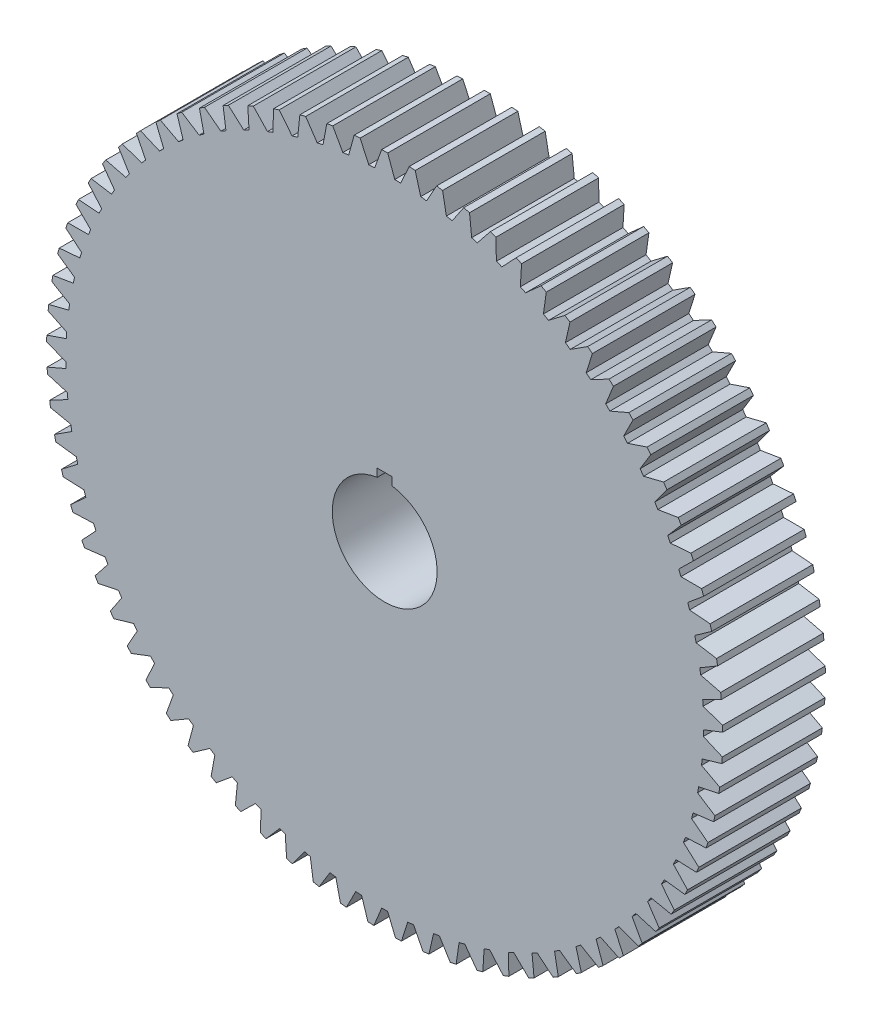
from build123d import *

# Parameters (mm, degrees)
BOSS_EXTRUDE1_DEPTH = 43.5102


with BuildPart() as part:
    # Sketch2 → Boss-Extrude1 (new body)
    with BuildSketch(Plane.XY):
        with BuildLine():
            Line((1.27, 143.32657345), (4.264662636, 135.098805479))
            ThreePointArc((4.264662636, 135.098805479), (5.513234102, 135.053614683), (6.76133452, 134.996884945))
            Line((6.76133452, 134.996884945), (10.416672135, 142.95318289))
            ThreePointArc((10.416672135, 142.95318289), (11.682904931, 142.855273929), (12.948220495, 142.74614931))
            Line((12.948220495, 142.74614931), (15.262279165, 134.301665752))
            ThreePointArc((15.262279165, 134.301665752), (16.503012644, 134.15485516), (17.74233611, 133.996582414))
            Line((17.74233611, 133.996582414), (22.034023036, 141.628462484))
            ThreePointArc((22.034023036, 141.628462484), (23.288062058, 141.427669579), (24.540272719, 141.215773098))
            Line((24.540272719, 141.215773098), (26.158327745, 132.610770599))
            ThreePointArc((26.158327745, 132.610770599), (27.382966359, 132.363317209), (28.605265381, 132.104554735))
            Line((28.605265381, 132.104554735), (33.504741149, 139.361228028))
            ThreePointArc((33.504741149, 139.361228028), (34.738240973, 139.058887422), (35.969013476, 138.745629215))
            Line((35.969013476, 138.745629215), (36.88029697, 130.037372646))
            ThreePointArc((36.88029697, 130.037372646), (38.080690951, 129.690923221), (39.277831329, 129.33339304))
            Line((39.277831329, 129.33339304), (44.752490738, 136.166567591))
            ThreePointArc((44.752490738, 136.166567591), (45.957242627, 135.764691312), (47.158386384, 135.352156062))
            Line((47.158386384, 135.352156062), (47.356833903, 126.598597433))
            ThreePointArc((47.356833903, 126.598597433), (48.524994828, 126.155457536), (49.689009791, 125.701538953))
            Line((49.689009791, 125.701538953), (55.702419884, 132.065741114))
            ThreePointArc((55.702419884, 132.065741114), (56.870406413, 131.567003581), (58.033928011, 131.057936641))
            Line((58.033928011, 131.057936641), (57.518218919, 122.317329441))
            ThreePointArc((57.518218919, 122.317329441), (58.64637287, 121.780448096), (59.769516091, 121.233161864))
            Line((59.769516091, 121.233161864), (66.281658616, 127.086038918))
            ThreePointArc((66.281658616, 127.086038918), (67.405107027, 126.493759148), (68.523263421, 125.891548274))
            Line((68.523263421, 125.891548274), (67.296829679, 117.222059803))
            ThreePointArc((67.296829679, 117.222059803), (68.377468977, 116.595009866), (69.452266123, 115.957998084))
            Line((69.452266123, 115.957998084), (76.419803846, 121.260600101))
            ThreePointArc((76.419803846, 121.260600101), (77.491237776, 120.578719618), (78.55658782, 119.887372425))
            Line((78.55658782, 119.887372425), (76.62759114, 111.346696697))
            ThreePointArc((76.62759114, 111.346696697), (77.653524309, 110.633651082), (78.672822782, 109.911152959))
            Line((78.672822782, 109.911152959), (86.04938789, 114.628191997))
            ThreePointArc((86.04938789, 114.628191997), (87.061677122, 113.861248604), (88.067131087, 113.085365892))
            Line((88.067131087, 113.085365892), (85.448408625, 104.730339695))
            ThreePointArc((85.448408625, 104.730339695), (86.412808248, 103.936043603), (87.369824786, 103.132867245))
            Line((87.369824786, 103.132867245), (95.106327454, 107.232952188))
            ThreePointArc((95.106327454, 107.232952188), (96.052735371, 106.386049765), (96.991602127, 105.530794907))
            Line((96.991602127, 105.530794907), (93.700581048, 97.417019562))
            ThreePointArc((93.700581048, 97.417019562), (94.597029206, 96.546758902), (95.48539502, 95.668249315))
            Line((95.48539502, 95.668249315), (103.530350101, 99.124094774))
            ThreePointArc((103.530350101, 99.124094774), (104.404578513, 98.202869318), (105.270610057, 97.273933893))
            Line((105.270610057, 97.273933893), (101.329191565, 89.455405237))
            ThreePointArc((101.329191565, 89.455405237), (102.151722542, 88.514971451), (102.965525705, 87.56697497))
            Line((102.965525705, 87.56697497), (111.265395349, 90.355582864))
            ThreePointArc((111.265395349, 90.355582864), (112.061626411, 89.366164978), (112.849059446, 88.369730899))
            Line((112.849059446, 88.369730899), (108.283473029, 80.898479949))
            ThreePointArc((108.283473029, 80.898479949), (109.026613018, 79.894131467), (109.760437805, 78.882956854))
            Line((109.760437805, 78.882956854), (118.259987748, 80.985769457))
            ThreePointArc((118.259987748, 80.985769457), (118.972922675, 79.934743554), (119.676516962, 78.877441925))
            Line((119.676516962, 78.877441925), (114.517145846, 71.803188624))
            ThreePointArc((114.517145846, 71.803188624), (115.175949373, 70.741609221), (115.8249123, 69.673985676))
            Line((115.8249123, 69.673985676), (124.467579441, 71.077009117))
            ThreePointArc((124.467579441, 71.077009117), (125.092473767, 69.971369601), (125.707547004, 68.860236588))
            Line((125.707547004, 68.860236588), (119.988725951, 62.230058925))
            ThreePointArc((119.988725951, 62.230058925), (120.558808788, 61.118313237), (121.118591113, 60.001345617))
            Line((121.118591113, 60.001345617), (129.846859928, 60.695243007))
            ThreePointArc((129.846859928, 60.695243007), (130.379555085, 59.542347727), (130.902014061, 58.384777739))
            Line((130.902014061, 58.384777739), (124.661800882, 52.242798452))
            ThreePointArc((124.661800882, 52.242798452), (125.13936922, 51.088284962), (125.606245686, 49.929406504))
            Line((125.606245686, 49.929406504), (134.362030985, 49.90956007))
            ThreePointArc((134.362030985, 49.90956007), (134.798981974, 48.717081352), (135.225349811, 47.520777827))
            Line((135.225349811, 47.520777827), (128.505272096, 41.907870774))
            ThreePointArc((128.505272096, 41.907870774), (128.887147797, 40.71827258), (129.258011418, 39.525195428))
            Line((129.258011418, 39.525195428), (137.983044895, 38.791737244))
            ThreePointArc((137.983044895, 38.791737244), (138.32134388, 37.567610839), (138.648783169, 36.340534978))
            Line((138.648783169, 36.340534978), (131.493561926, 31.29405313))
            ThreePointArc((131.493561926, 31.29405313), (131.777203671, 30.077286811), (132.049586409, 28.857950697))
            Line((132.049586409, 28.857950697), (140.685804406, 27.415761808))
            ThreePointArc((140.685804406, 27.415761808), (140.923200063, 26.168134075), (141.149531751, 24.918451865))
            Line((141.149531751, 24.918451865), (133.606783796, 20.471978727))
            ThreePointArc((133.606783796, 20.471978727), (133.790303995, 19.236141662), (133.962393189, 17.998661066))
            Line((133.962393189, 17.998661066), (142.4523231, 15.857338999))
            ThreePointArc((142.4523231, 15.857338999), (142.5872356, 14.594512695), (142.710953487, 13.330540566))
            Line((142.710953487, 13.330540566), (134.830874563, 9.513666682))
            ThreePointArc((134.830874563, 9.513666682), (134.913051921, 8.266983163), (134.983702346, 7.019593315))
            Line((134.983702346, 7.019593315), (143.270845088, 4.193388216))
            ThreePointArc((143.270845088, 4.193388216), (143.30237661, 2.923767241), (143.322657373, 1.653916719))
            Line((143.322657373, 1.653916719), (135.157688106, -1.507957245))
            ThreePointArc((135.157688106, -1.507957245), (135.137975745, -2.757190745), (135.106717233, -4.006188672))
            Line((135.106717233, -4.006188672), (143.135923239, -7.498468873))
            ThreePointArc((143.135923239, -7.498468873), (143.063863946, -8.766435401), (142.98057262, -10.033713671))
            Line((142.98057262, -10.033713671), (134.585049534, -12.519545965))
            ThreePointArc((134.585049534, -12.519545965), (134.463578636, -13.763016003), (134.330619209, -15.005310133))
            Line((134.330619209, -15.005310133), (142.048455436, -19.14042489))
            ThreePointArc((142.048455436, -19.14042489), (141.873284872, -20.398298862), (141.686975747, -21.654571352))
            Line((141.686975747, -21.654571352), (133.116769662, -23.447819172))
            ThreePointArc((133.116769662, -23.447819172), (132.894348597, -24.677250661), (132.660573076, -25.904573732))
            Line((132.660573076, -25.904573732), (140.0156786, -30.655004536))
            ThreePointArc((140.0156786, -30.655004536), (139.738562494, -31.89441501), (139.450475427, -33.131321433))
            Line((139.450475427, -33.131321433), (130.762619651, -34.220051011))
            ThreePointArc((130.762619651, -34.220051011), (130.440728594, -35.427262286), (130.107692718, -36.631446666))
            Line((130.107692718, -36.631446666), (137.051120523, -41.965580186))
            ThreePointArc((137.051120523, -41.965580186), (136.673903039, -43.178279088), (136.285955201, -44.387588037))
            Line((136.285955201, -44.387588037), (127.53826598, -44.764554057))
            ThreePointArc((127.53826598, -44.764554057), (127.119047063, -45.941511327), (126.68896713, -47.114543367))
            Line((126.68896713, -47.114543367), (133.174509851, -52.996881823))
            ThreePointArc((133.174509851, -52.996881823), (132.699701308, -54.174798843), (132.214474429, -55.348462565))
            Line((132.214474429, -55.348462565), (123.465166192, -55.011156381))
            ThreePointArc((123.465166192, -55.011156381), (122.951409247, -56.150027189), (122.427147369, -57.284100554))
            Line((122.427147369, -57.284100554), (128.411644788, -63.675497955))
            ThreePointArc((128.411644788, -63.675497955), (127.842404959, -64.810794249), (127.263128143, -65.941002207))
            Line((127.263128143, -65.941002207), (118.570426093, -64.891668536))
            ThreePointArc((118.570426093, -64.891668536), (117.965550088, -65.984873884), (117.350595141, -67.072441504))
            Line((117.350595141, -67.072441504), (122.794221415, -73.930364154))
            ThreePointArc((122.794221415, -73.930364154), (122.134338497, -75.015484513), (121.464866736, -76.094715359))
            Line((121.464866736, -76.094715359), (112.886619371, -74.340337342))
            ThreePointArc((112.886619371, -74.340337342), (112.194649657, -75.380602131), (111.493094063, -76.414426422))
            Line((111.493094063, -76.414426422), (116.359622758, -83.693235977))
            ThreePointArc((116.359622758, -83.693235977), (115.613488164, -84.720959104), (114.858276682, -85.742030735))
            Line((114.858276682, -85.742030735), (106.451570822, -83.29428347))
            ThreePointArc((106.451570822, -83.29428347), (105.677112342, -84.274684907), (104.89362484, -85.247885939))
            Line((104.89362484, -85.247885939), (109.15067001, -92.899143124))
            ThreePointArc((109.15067001, -92.899143124), (108.323249141, -93.86262969), (107.487323746, -94.818747043))
            Line((107.487323746, -94.818747043), (99.308104633, -91.693919883))
            ThreePointArc((99.308104633, -91.693919883), (98.456311281, -92.60793356), (97.59610585, -93.514034841))
            Line((97.59610585, -93.514034841), (101.215337562, -101.4868218))
            ThreePointArc((101.215337562, -101.4868218), (100.312136768, -102.379659962), (99.401060405, -103.264460233))
            Line((99.401060405, -103.264460233), (91.503759392, -99.483348388))
            ThreePointArc((91.503759392, -99.483348388), (90.580299712, -100.324891693), (89.649100877, -101.157863269))
            Line((89.649100877, -101.157863269), (92.606433742, -109.399122421))
            ThreePointArc((92.606433742, -109.399122421), (91.633463675, -110.215370488), (90.653299407, -111.022965477))
            Line((90.653299407, -111.022965477), (83.090471729, -106.610731623))
            ThreePointArc((83.090471729, -106.610731623), (82.101491193, -107.374204226), (81.105495929, -108.128502807))
            Line((81.105495929, -108.128502807), (83.381249384, -116.583389932))
            ThreePointArc((83.381249384, -116.583389932), (82.344984999, -117.317615908), (81.302255659, -118.042631204))
            Line((81.302255659, -118.042631204), (74.124230686, -113.028638028))
            ThreePointArc((74.124230686, -113.028638028), (73.076310796, -113.708959144), (72.022147288, -114.379564999))
            Line((72.022147288, -114.379564999), (73.601176568, -122.991814218))
            ThreePointArc((73.601176568, -122.991814218), (72.508514034, -123.63913195), (71.410158812, -124.276742696))
            Line((71.410158812, -124.276742696), (64.664705117, -118.694357496))
            ThreePointArc((64.664705117, -118.694357496), (63.564819608, -119.2869997), (62.459503138, -119.869450057))
            Line((62.459503138, -119.869450057), (63.331300066, -128.581748273))
            ThreePointArc((63.331300066, -128.581748273), (62.189510872, -129.137849968), (61.042839141, -129.68381297))
            Line((61.042839141, -129.68381297), (54.774846604, -123.570185598))
            ThreePointArc((54.774846604, -123.570185598), (53.630315032, -124.071204954), (52.481201301, -124.561623702))
            Line((52.481201301, -124.561623702), (52.63996421, -133.315992007))
            ThreePointArc((52.63996421, -133.315992007), (51.456646775, -133.777176901), (50.269289447, -134.227858865))
            Line((50.269289447, -134.227858865), (44.520470525, -127.623674502))
            ThreePointArc((44.520470525, -127.623674502), (43.338909559, -128.029736809), (42.153645728, -128.424860292))
            Line((42.153645728, -128.424860292), (41.598318078, -137.16303981))
            ThreePointArc((41.598318078, -137.16303981), (40.381347184, -137.526238793), (39.161205925, -137.878640504))
            Line((39.161205925, -137.878640504), (33.96981806, -130.827848909))
            ThreePointArc((33.96981806, -130.827848909), (32.759090792, -131.13625189), (31.545564597, -131.433450626))
            Line((31.545564597, -131.433450626), (30.279842002, -140.097290214))
            ThreePointArc((30.279842002, -140.097290214), (29.037316389, -140.360086256), (27.792511039, -140.61186254))
            Line((27.792511039, -140.61186254), (23.19310206, -133.161385567))
            ThreePointArc((23.19310206, -133.161385567), (21.961265681, -133.37007685), (20.727552938, -133.567373031))
            Line((20.727552938, -133.567373031), (18.759858573, -142.099216265))
            ThreePointArc((18.759858573, -142.099216265), (17.500047045, -142.259860503), (16.238861577, -142.40933583))
            Line((16.238861577, -142.40933583), (12.262039792, -134.608755173))
            ThreePointArc((12.262039792, -134.608755173), (11.017291971, -134.716345953), (9.771602835, -134.812426605))
            Line((9.771602835, -134.812426605), (7.115031381, -143.155495477))
            ThreePointArc((7.115031381, -143.155495477), (5.846317775, -143.212918849), (4.577145171, -143.259098486))
            Line((4.577145171, -143.259098486), (1.249375673, -135.160325723))
            ThreePointArc((1.249375673, -135.160325723), (0, -135.1661), (-1.249375673, -135.160325723))
            Line((-1.249375673, -135.160325723), (-4.577145171, -143.259098486))
            ThreePointArc((-4.577145171, -143.259098486), (-5.846317775, -143.212918849), (-7.115031381, -143.155495477))
            Line((-7.115031381, -143.155495477), (-9.771602835, -134.812426605))
            ThreePointArc((-9.771602835, -134.812426605), (-11.017291971, -134.716345953), (-12.262039792, -134.608755173))
            Line((-12.262039792, -134.608755173), (-16.238861577, -142.40933583))
            ThreePointArc((-16.238861577, -142.40933583), (-17.500047045, -142.259860503), (-18.759858573, -142.099216265))
            Line((-18.759858573, -142.099216265), (-20.727552938, -133.567373031))
            ThreePointArc((-20.727552938, -133.567373031), (-21.961265681, -133.37007685), (-23.19310206, -133.161385567))
            Line((-23.19310206, -133.161385567), (-27.792511039, -140.61186254))
            ThreePointArc((-27.792511039, -140.61186254), (-29.037316389, -140.360086256), (-30.279842002, -140.097290214))
            Line((-30.279842002, -140.097290214), (-31.545564597, -131.433450626))
            ThreePointArc((-31.545564597, -131.433450626), (-32.759090792, -131.13625189), (-33.96981806, -130.827848909))
            Line((-33.96981806, -130.827848909), (-39.161205925, -137.878640504))
            ThreePointArc((-39.161205925, -137.878640504), (-40.381347184, -137.526238793), (-41.598318078, -137.16303981))
            Line((-41.598318078, -137.16303981), (-42.153645728, -128.424860292))
            ThreePointArc((-42.153645728, -128.424860292), (-43.338909559, -128.029736809), (-44.520470525, -127.623674502))
            Line((-44.520470525, -127.623674502), (-50.269289447, -134.227858865))
            ThreePointArc((-50.269289447, -134.227858865), (-51.456646775, -133.777176901), (-52.63996421, -133.315992007))
            Line((-52.63996421, -133.315992007), (-52.481201301, -124.561623702))
            ThreePointArc((-52.481201301, -124.561623702), (-53.630315032, -124.071204954), (-54.774846604, -123.570185598))
            Line((-54.774846604, -123.570185598), (-61.042839141, -129.68381297))
            ThreePointArc((-61.042839141, -129.68381297), (-62.189510872, -129.137849968), (-63.331300066, -128.581748273))
            Line((-63.331300066, -128.581748273), (-62.459503138, -119.869450057))
            ThreePointArc((-62.459503138, -119.869450057), (-63.564819608, -119.2869997), (-64.664705117, -118.694357496))
            Line((-64.664705117, -118.694357496), (-71.410158812, -124.276742696))
            ThreePointArc((-71.410158812, -124.276742696), (-72.508514034, -123.63913195), (-73.601176568, -122.991814218))
            Line((-73.601176568, -122.991814218), (-72.022147288, -114.379564999))
            ThreePointArc((-72.022147288, -114.379564999), (-73.076310796, -113.708959144), (-74.124230686, -113.028638028))
            Line((-74.124230686, -113.028638028), (-81.302255659, -118.042631204))
            ThreePointArc((-81.302255659, -118.042631204), (-82.344984999, -117.317615908), (-83.381249384, -116.583389932))
            Line((-83.381249384, -116.583389932), (-81.105495929, -108.128502807))
            ThreePointArc((-81.105495929, -108.128502807), (-82.101491193, -107.374204226), (-83.090471729, -106.610731623))
            Line((-83.090471729, -106.610731623), (-90.653299407, -111.022965477))
            ThreePointArc((-90.653299407, -111.022965477), (-91.633463675, -110.215370488), (-92.606433742, -109.399122421))
            Line((-92.606433742, -109.399122421), (-89.649100877, -101.157863269))
            ThreePointArc((-89.649100877, -101.157863269), (-90.580299712, -100.324891693), (-91.503759392, -99.483348388))
            Line((-91.503759392, -99.483348388), (-99.401060405, -103.264460233))
            ThreePointArc((-99.401060405, -103.264460233), (-100.312136768, -102.379659962), (-101.215337562, -101.4868218))
            Line((-101.215337562, -101.4868218), (-97.59610585, -93.514034841))
            ThreePointArc((-97.59610585, -93.514034841), (-98.456311281, -92.60793356), (-99.308104633, -91.693919883))
            Line((-99.308104633, -91.693919883), (-107.487323746, -94.818747043))
            ThreePointArc((-107.487323746, -94.818747043), (-108.323249141, -93.86262969), (-109.15067001, -92.899143124))
            Line((-109.15067001, -92.899143124), (-104.89362484, -85.247885939))
            ThreePointArc((-104.89362484, -85.247885939), (-105.677112342, -84.274684907), (-106.451570822, -83.29428347))
            Line((-106.451570822, -83.29428347), (-114.858276682, -85.742030735))
            ThreePointArc((-114.858276682, -85.742030735), (-115.613488164, -84.720959104), (-116.359622758, -83.693235977))
            Line((-116.359622758, -83.693235977), (-111.493094063, -76.414426422))
            ThreePointArc((-111.493094063, -76.414426422), (-112.194649657, -75.380602131), (-112.886619371, -74.340337342))
            Line((-112.886619371, -74.340337342), (-121.464866736, -76.094715359))
            ThreePointArc((-121.464866736, -76.094715359), (-122.134338497, -75.015484513), (-122.794221415, -73.930364154))
            Line((-122.794221415, -73.930364154), (-117.350595141, -67.072441504))
            ThreePointArc((-117.350595141, -67.072441504), (-117.965550088, -65.984873884), (-118.570426093, -64.891668536))
            Line((-118.570426093, -64.891668536), (-127.263128143, -65.941002207))
            ThreePointArc((-127.263128143, -65.941002207), (-127.842404959, -64.810794249), (-128.411644788, -63.675497955))
            Line((-128.411644788, -63.675497955), (-122.427147369, -57.284100554))
            ThreePointArc((-122.427147369, -57.284100554), (-122.951409247, -56.150027189), (-123.465166192, -55.011156381))
            Line((-123.465166192, -55.011156381), (-132.214474429, -55.348462565))
            ThreePointArc((-132.214474429, -55.348462565), (-132.699701308, -54.174798843), (-133.174509851, -52.996881823))
            Line((-133.174509851, -52.996881823), (-126.68896713, -47.114543367))
            ThreePointArc((-126.68896713, -47.114543367), (-127.119047063, -45.941511327), (-127.53826598, -44.764554057))
            Line((-127.53826598, -44.764554057), (-136.285955201, -44.387588037))
            ThreePointArc((-136.285955201, -44.387588037), (-136.673903039, -43.178279088), (-137.051120523, -41.965580186))
            Line((-137.051120523, -41.965580186), (-130.107692718, -36.631446666))
            ThreePointArc((-130.107692718, -36.631446666), (-130.440728594, -35.427262286), (-130.762619651, -34.220051011))
            Line((-130.762619651, -34.220051011), (-139.450475427, -33.131321433))
            ThreePointArc((-139.450475427, -33.131321433), (-139.738562494, -31.89441501), (-140.0156786, -30.655004536))
            Line((-140.0156786, -30.655004536), (-132.660573076, -25.904573732))
            ThreePointArc((-132.660573076, -25.904573732), (-132.894348597, -24.677250661), (-133.116769662, -23.447819172))
            Line((-133.116769662, -23.447819172), (-141.686975747, -21.654571352))
            ThreePointArc((-141.686975747, -21.654571352), (-141.873284872, -20.398298862), (-142.048455436, -19.14042489))
            Line((-142.048455436, -19.14042489), (-134.330619209, -15.005310133))
            ThreePointArc((-134.330619209, -15.005310133), (-134.463578636, -13.763016003), (-134.585049534, -12.519545965))
            Line((-134.585049534, -12.519545965), (-142.98057262, -10.033713671))
            ThreePointArc((-142.98057262, -10.033713671), (-143.063863946, -8.766435401), (-143.135923239, -7.498468873))
            Line((-143.135923239, -7.498468873), (-135.106717233, -4.006188672))
            ThreePointArc((-135.106717233, -4.006188672), (-135.137975745, -2.757190745), (-135.157688106, -1.507957245))
            Line((-135.157688106, -1.507957245), (-143.322657373, 1.653916719))
            ThreePointArc((-143.322657373, 1.653916719), (-143.30237661, 2.923767241), (-143.270845088, 4.193388216))
            Line((-143.270845088, 4.193388216), (-134.983702346, 7.019593315))
            ThreePointArc((-134.983702346, 7.019593315), (-134.913051921, 8.266983163), (-134.830874563, 9.513666682))
            Line((-134.830874563, 9.513666682), (-142.710953487, 13.330540566))
            ThreePointArc((-142.710953487, 13.330540566), (-142.5872356, 14.594512695), (-142.4523231, 15.857338999))
            Line((-142.4523231, 15.857338999), (-133.962393189, 17.998661066))
            ThreePointArc((-133.962393189, 17.998661066), (-133.790303995, 19.236141662), (-133.606783796, 20.471978727))
            Line((-133.606783796, 20.471978727), (-141.149531751, 24.918451865))
            ThreePointArc((-141.149531751, 24.918451865), (-140.923200063, 26.168134075), (-140.685804406, 27.415761808))
            Line((-140.685804406, 27.415761808), (-132.049586409, 28.857950697))
            ThreePointArc((-132.049586409, 28.857950697), (-131.777203671, 30.077286811), (-131.493561926, 31.29405313))
            Line((-131.493561926, 31.29405313), (-138.648783169, 36.340534978))
            ThreePointArc((-138.648783169, 36.340534978), (-138.32134388, 37.567610839), (-137.983044895, 38.791737244))
            Line((-137.983044895, 38.791737244), (-129.258011418, 39.525195428))
            ThreePointArc((-129.258011418, 39.525195428), (-128.887147797, 40.71827258), (-128.505272096, 41.907870774))
            Line((-128.505272096, 41.907870774), (-135.225349811, 47.520777827))
            ThreePointArc((-135.225349811, 47.520777827), (-134.798981974, 48.717081352), (-134.362030985, 49.90956007))
            Line((-134.362030985, 49.90956007), (-125.606245686, 49.929406504))
            ThreePointArc((-125.606245686, 49.929406504), (-125.13936922, 51.088284962), (-124.661800882, 52.242798452))
            Line((-124.661800882, 52.242798452), (-130.902014061, 58.384777739))
            ThreePointArc((-130.902014061, 58.384777739), (-130.379555085, 59.542347727), (-129.846859928, 60.695243007))
            Line((-129.846859928, 60.695243007), (-121.118591113, 60.001345617))
            ThreePointArc((-121.118591113, 60.001345617), (-120.558808788, 61.118313237), (-119.988725951, 62.230058925))
            Line((-119.988725951, 62.230058925), (-125.707547004, 68.860236588))
            ThreePointArc((-125.707547004, 68.860236588), (-125.092473767, 69.971369601), (-124.467579441, 71.077009117))
            Line((-124.467579441, 71.077009117), (-115.8249123, 69.673985676))
            ThreePointArc((-115.8249123, 69.673985676), (-115.175949373, 70.741609221), (-114.517145846, 71.803188624))
            Line((-114.517145846, 71.803188624), (-119.676516962, 78.877441925))
            ThreePointArc((-119.676516962, 78.877441925), (-118.972922675, 79.934743554), (-118.259987748, 80.985769457))
            Line((-118.259987748, 80.985769457), (-109.760437805, 78.882956854))
            ThreePointArc((-109.760437805, 78.882956854), (-109.026613018, 79.894131467), (-108.283473029, 80.898479949))
            Line((-108.283473029, 80.898479949), (-112.849059446, 88.369730899))
            ThreePointArc((-112.849059446, 88.369730899), (-112.061626411, 89.366164978), (-111.265395349, 90.355582864))
            Line((-111.265395349, 90.355582864), (-102.965525705, 87.56697497))
            ThreePointArc((-102.965525705, 87.56697497), (-102.151722542, 88.514971451), (-101.329191565, 89.455405237))
            Line((-101.329191565, 89.455405237), (-105.270610057, 97.273933893))
            ThreePointArc((-105.270610057, 97.273933893), (-104.404578513, 98.202869318), (-103.530350101, 99.124094774))
            Line((-103.530350101, 99.124094774), (-95.48539502, 95.668249315))
            ThreePointArc((-95.48539502, 95.668249315), (-94.597029206, 96.546758902), (-93.700581048, 97.417019562))
            Line((-93.700581048, 97.417019562), (-96.991602127, 105.530794907))
            ThreePointArc((-96.991602127, 105.530794907), (-96.052735371, 106.386049765), (-95.106327454, 107.232952188))
            Line((-95.106327454, 107.232952188), (-87.369824786, 103.132867245))
            ThreePointArc((-87.369824786, 103.132867245), (-86.412808248, 103.936043603), (-85.448408625, 104.730339695))
            Line((-85.448408625, 104.730339695), (-88.067131087, 113.085365892))
            ThreePointArc((-88.067131087, 113.085365892), (-87.061677122, 113.861248604), (-86.04938789, 114.628191997))
            Line((-86.04938789, 114.628191997), (-78.672822782, 109.911152959))
            ThreePointArc((-78.672822782, 109.911152959), (-77.653524309, 110.633651082), (-76.62759114, 111.346696697))
            Line((-76.62759114, 111.346696697), (-78.55658782, 119.887372425))
            ThreePointArc((-78.55658782, 119.887372425), (-77.491237776, 120.578719618), (-76.419803846, 121.260600101))
            Line((-76.419803846, 121.260600101), (-69.452266123, 115.957998084))
            ThreePointArc((-69.452266123, 115.957998084), (-68.377468977, 116.595009866), (-67.296829679, 117.222059803))
            Line((-67.296829679, 117.222059803), (-68.523263421, 125.891548274))
            ThreePointArc((-68.523263421, 125.891548274), (-67.405107027, 126.493759148), (-66.281658616, 127.086038918))
            Line((-66.281658616, 127.086038918), (-59.769516091, 121.233161864))
            ThreePointArc((-59.769516091, 121.233161864), (-58.64637287, 121.780448096), (-57.518218919, 122.317329441))
            Line((-57.518218919, 122.317329441), (-58.033928011, 131.057936641))
            ThreePointArc((-58.033928011, 131.057936641), (-56.870406413, 131.567003581), (-55.702419884, 132.065741114))
            Line((-55.702419884, 132.065741114), (-49.689009791, 125.701538953))
            ThreePointArc((-49.689009791, 125.701538953), (-48.524994828, 126.155457536), (-47.356833903, 126.598597433))
            Line((-47.356833903, 126.598597433), (-47.158386384, 135.352156062))
            ThreePointArc((-47.158386384, 135.352156062), (-45.957242627, 135.764691312), (-44.752490738, 136.166567591))
            Line((-44.752490738, 136.166567591), (-39.277831329, 129.33339304))
            ThreePointArc((-39.277831329, 129.33339304), (-38.080690951, 129.690923221), (-36.88029697, 130.037372646))
            Line((-36.88029697, 130.037372646), (-35.969013476, 138.745629215))
            ThreePointArc((-35.969013476, 138.745629215), (-34.738240973, 139.058887422), (-33.504741149, 139.361228028))
            Line((-33.504741149, 139.361228028), (-28.605265381, 132.104554735))
            ThreePointArc((-28.605265381, 132.104554735), (-27.382966359, 132.363317209), (-26.158327745, 132.610770599))
            Line((-26.158327745, 132.610770599), (-24.540272719, 141.215773098))
            ThreePointArc((-24.540272719, 141.215773098), (-23.288062058, 141.427669579), (-22.034023036, 141.628462484))
            Line((-22.034023036, 141.628462484), (-17.74233611, 133.996582414))
            ThreePointArc((-17.74233611, 133.996582414), (-16.503012644, 134.15485516), (-15.262279165, 134.301665752))
            Line((-15.262279165, 134.301665752), (-12.948220495, 142.74614931))
            ThreePointArc((-12.948220495, 142.74614931), (-11.682904931, 142.855273929), (-10.416672135, 142.95318289))
            Line((-10.416672135, 142.95318289), (-6.76133452, 134.996884945))
            ThreePointArc((-6.76133452, 134.996884945), (-5.513234102, 135.053614683), (-4.264662636, 135.098805479))
            Line((-4.264662636, 135.098805479), (-1.27, 143.32657345))
            ThreePointArc((-1.27, 143.32657345), (0, 143.3322), (1.27, 143.32657345))
        make_face()
        with BuildLine():
            Line((0, 25.4), (-3.175, 25.4))
            Line((-3.175, 25.4), (-3.175, 21.997045256))
            ThreePointArc((-3.175, 21.997045256), (0, -22.225), (3.175, 21.997045256))
            Line((3.175, 21.997045256), (3.175, 25.4))
            Line((3.175, 25.4), (0, 25.4))
        make_face(mode=Mode.SUBTRACT)
    extrude(amount=BOSS_EXTRUDE1_DEPTH)


solid = part.part
